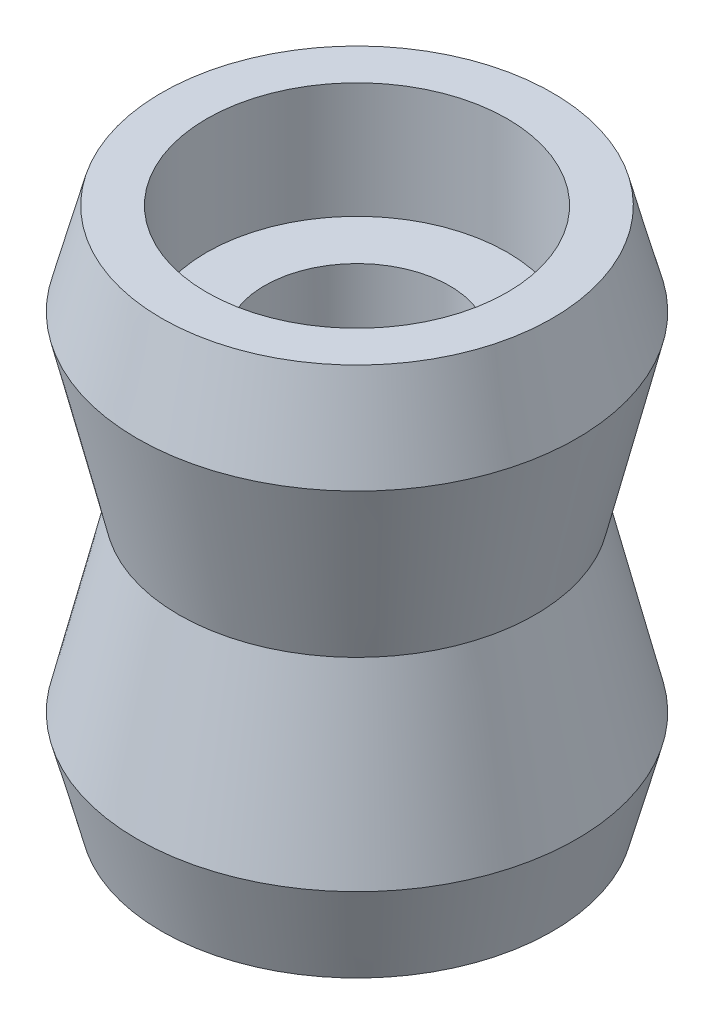
from build123d import *

# Parameters (mm, degrees)
SKETCH2_R           = 4
BOSS_EXTRUDE1_DEPTH = 0.2


with BuildPart() as part:
    # Sketch1 → Revolve1 (revolve)
    with BuildSketch(Plane.XY):
        Polygon((4, -3.284366974), (4, 9.669000537), (6.5, 9.669000537), (6.5, 14.669000537), (8.448345124, 14.669000537), (9.5, 10.692316782), (7.7, 3.192316782), (9.5, -4.307683218), (8.448345124, -8.284366974), (6.5, -8.284366974), (6.5, -3.284366974), align=None)
    revolve(axis=Axis((0, 42.323455848, 0), (0, -1, 0)))

    # Sketch2 → Boss-Extrude1 (add)
    with BuildSketch(Plane.XZ.offset(3.284366974)):
        Circle(SKETCH2_R)
    extrude(amount=-BOSS_EXTRUDE1_DEPTH)


solid = part.part
